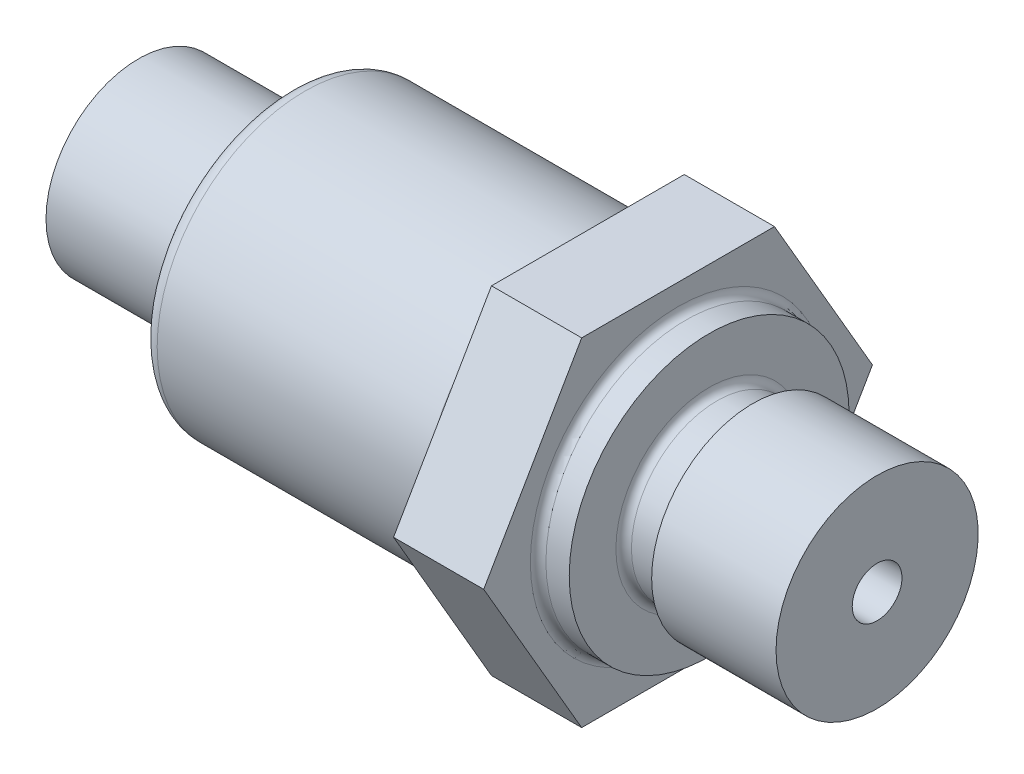
from build123d import *

# Parameters (mm, degrees)
SKETCH2_OUTSIDE_W  = 38.842
SKETCH2_OUTSIDE_H  = 38.842
CUT_EXTRUDE1_DEPTH = 5.8


with BuildPart() as part:
    # Sketch1 → Revolve1 (revolve)
    with BuildSketch(Plane.XY):
        with BuildLine():
            Line((0, 4.1), (0, 5.95))
            Line((0, 5.95), (9.7, 5.95))
            Line((9.7, 5.95), (9.7, 8.5))
            ThreePointArc((9.7, 8.5), (9.992893219, 9.207106781), (10.7, 9.5))
            Line((10.7, 9.5), (27.9, 9.5))
            ThreePointArc((27.9, 9.5), (28.607106781, 9.792893219), (28.9, 10.5))
            Line((28.9, 10.5), (28.9, 12.5))
            Line((28.9, 12.5), (34.7, 12.5))
            Line((34.7, 12.5), (34.7, 9.5))
            ThreePointArc((34.7, 9.5), (34.846446609, 9.146446609), (35.2, 9))
            Line((35.2, 9), (36.7, 9))
            Line((36.7, 9), (36.7, 6.5))
            Line((36.7, 6.5), (36.7, 6))
            ThreePointArc((36.7, 6), (36.846446609, 5.646446609), (37.2, 5.5))
            Line((37.2, 5.5), (39, 5.5))
            ThreePointArc((39, 5.5), (39.353553391, 5.646446609), (39.5, 6))
            Line((39.5, 6), (39.5, 6.5))
            Line((39.5, 6.5), (47.5, 6.5))
            Line((47.5, 6.5), (47.5, 1.6))
            Line((47.5, 1.6), (32.5, 1.6))
            Line((32.5, 1.6), (32.5, 0))
            Line((32.5, 0), (9.4, 0))
            Line((9.4, 0), (9.4, 4.1))
            Line((9.4, 4.1), (0, 4.1))
        make_face()
    revolve(axis=Axis((0, 0, 0), (1, 0, 0)))

    # Sketch2 outside → Cut-Extrude1 (cut)
    with BuildSketch(Plane(origin=(28.9, 0, 0), x_dir=(0, 0, -1), z_dir=(1, 0, 0))):
        Rectangle(SKETCH2_OUTSIDE_W, SKETCH2_OUTSIDE_H)
        Polygon((6.2, 10.854031509), (12.5, 0), (6.2, -10.854031509), (-6.2, -10.854031509), (-12.5, 0), (-6.2, 10.854031509), align=None, mode=Mode.SUBTRACT)
    extrude(amount=CUT_EXTRUDE1_DEPTH, mode=Mode.SUBTRACT)


solid = part.part
